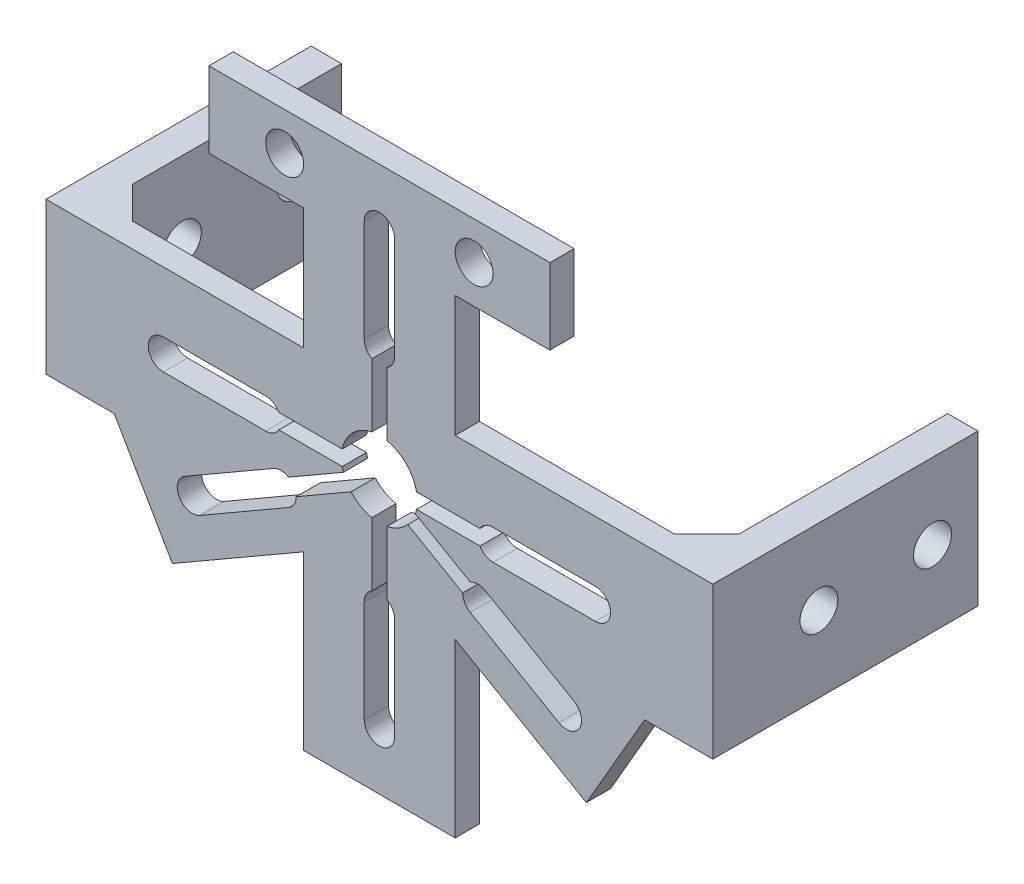
from build123d import *

# Parameters (mm, degrees)
BOSS_EXTRUDE1_DEPTH = 3.2
SKETCH2_W           = 4
SKETCH2_H           = 20
BOSS_EXTRUDE2_DEPTH = 35
BOSS_EXTRUDE3_DEPTH = 20
CUT_EXTRUDE1_REACH  = 102.256
SKETCH4_R           = 2.5
SKETCH5_R           = 2.5
CUT_EXTRUDE2_DEPTH  = 3.2


with BuildPart() as part:
    # Sketch1 → Boss-Extrude1 (new body)
    with BuildSketch(Plane.XY):
        Polygon((22.5, 36), (-22.5, 36), (-22.5, 26), (-10, 26), (-10, 10), (-40, 10), (-40, -10), (-35, -10), (-27.320508076, -23.301270189), (-10, -13.301270189), (-10, -36), (10, -36), (10, -13.301270189), (27.320508076, -23.301270189), (35, -10), (40, -10), (40, 10), (10, 10), (10, 26), (22.5, 26), align=None)
        with BuildLine():
            Line((2, 28.5), (2, 15))
            ThreePointArc((2, 15), (1.732050808, 14), (1, 13.267949192))
            Line((1, 13.267949192), (1, 4.898979486))
            ThreePointArc((1, 4.898979486), (3.535533906, 3.535533906), (4.898979486, 1))
            Line((4.898979486, 1), (13.267949192, 1))
            ThreePointArc((13.267949192, 1), (14, 1.732050808), (15, 2))
            Line((15, 2), (28.5, 2))
            ThreePointArc((28.5, 2), (30.5, 0), (28.5, -2))
            Line((28.5, -2), (15, -2))
            ThreePointArc((15, -2), (14, -1.732050808), (13.267949192, -1))
            Line((13.267949192, -1), (4.898979486, -1))
            ThreePointArc((4.898979486, -1), (4.829629131, -1.294095226), (4.742640687, -1.583464339))
            Line((4.742640687, -1.583464339), (11.990381057, -5.767949192))
            ThreePointArc((11.990381057, -5.767949192), (12.990381057, -5.5), (13.990381057, -5.767949192))
            Line((13.990381057, -5.767949192), (25.681724008, -12.517949192))
            ThreePointArc((25.681724008, -12.517949192), (26.413774815, -15.25), (23.681724008, -15.982050808))
            Line((23.681724008, -15.982050808), (11.990381057, -9.232050808))
            ThreePointArc((11.990381057, -9.232050808), (11.258330249, -8.5), (10.990381057, -7.5))
            Line((10.990381057, -7.5), (3.742640687, -3.315515147))
            ThreePointArc((3.742640687, -3.315515147), (2.5, -4.330127019), (1, -4.898979486))
            Line((1, -4.898979486), (1, -13.267949192))
            ThreePointArc((1, -13.267949192), (1.732050808, -14), (2, -15))
            Line((2, -15), (2, -28.5))
            ThreePointArc((2, -28.5), (0, -30.5), (-2, -28.5))
            Line((-2, -28.5), (-2, -15))
            ThreePointArc((-2, -15), (-1.732050808, -14), (-1, -13.267949192))
            Line((-1, -13.267949192), (-1, -4.898979486))
            ThreePointArc((-1, -4.898979486), (-2.5, -4.330127019), (-3.742640687, -3.315515147))
            Line((-3.742640687, -3.315515147), (-10.990381057, -7.5))
            ThreePointArc((-10.990381057, -7.5), (-11.258330249, -8.5), (-11.990381057, -9.232050808))
            Line((-11.990381057, -9.232050808), (-23.681724008, -15.982050808))
            ThreePointArc((-23.681724008, -15.982050808), (-26.413774815, -15.25), (-25.681724008, -12.517949192))
            Line((-25.681724008, -12.517949192), (-13.990381057, -5.767949192))
            ThreePointArc((-13.990381057, -5.767949192), (-12.990381057, -5.5), (-11.990381057, -5.767949192))
            Line((-11.990381057, -5.767949192), (-4.742640687, -1.583464339))
            ThreePointArc((-4.742640687, -1.583464339), (-4.829629131, -1.294095226), (-4.898979486, -1))
            Line((-4.898979486, -1), (-13.267949192, -1))
            ThreePointArc((-13.267949192, -1), (-14, -1.732050808), (-15, -2))
            Line((-15, -2), (-28.5, -2))
            ThreePointArc((-28.5, -2), (-30.5, 0), (-28.5, 2))
            Line((-28.5, 2), (-15, 2))
            ThreePointArc((-15, 2), (-14, 1.732050808), (-13.267949192, 1))
            Line((-13.267949192, 1), (-4.898979486, 1))
            ThreePointArc((-4.898979486, 1), (-3.535533906, 3.535533906), (-1, 4.898979486))
            Line((-1, 4.898979486), (-1, 13.267949192))
            ThreePointArc((-1, 13.267949192), (-1.732050808, 14), (-2, 15))
            Line((-2, 15), (-2, 28.5))
            ThreePointArc((-2, 28.5), (0, 30.5), (2, 28.5))
        make_face(mode=Mode.SUBTRACT)
    extrude(amount=BOSS_EXTRUDE1_DEPTH)

    # Sketch2 → Boss-Extrude2 (add)
    with BuildSketch(Plane(origin=(0, 0, 3.2), x_dir=(-1, 0, 0), z_dir=(0, 0, -1))):
        with Locations((42, 0)):
            Rectangle(SKETCH2_W, SKETCH2_H)
        with Locations((-42, 0)):
            Rectangle(SKETCH2_W, SKETCH2_H)
    extrude(amount=BOSS_EXTRUDE2_DEPTH)

    # Sketch3 → Boss-Extrude3 (add)
    with BuildSketch(Plane(origin=(0, 10, 0), x_dir=(1, 0, 0), z_dir=(0, 1, 0))):
        Polygon((-40, 4.242640687), (-35.757359313, 0), (-40, 0), align=None)
        Polygon((35.757359313, 0), (40, 0), (40, 4.242640687), align=None)
    extrude(amount=-BOSS_EXTRUDE3_DEPTH)

    # Cut-Extrude1: up to this face of the body (flat: up to its plane)
    cut_extrude1_end = Plane(part.part.faces().sort_by_distance((44, 0, -14.3))[0])
    # Sketch4 → Cut-Extrude1 (cut, up to the picked face)
    with BuildSketch(Plane.ZY.offset(44), mode=Mode.PRIVATE) as cut_extrude1_sk1:
        with Locations((-25.8, 0)):
            Circle(SKETCH4_R)
    cut_extrude1_tool1 = split(extrude(cut_extrude1_sk1.sketch, amount=-CUT_EXTRUDE1_REACH, mode=Mode.PRIVATE), bisect_by=cut_extrude1_end, keep=Keep.BOTH, mode=Mode.PRIVATE)
    # Sketch4 → Cut-Extrude1 (cut, up to the picked face)
    with BuildSketch(Plane.ZY.offset(44), mode=Mode.PRIVATE) as cut_extrude1_sk2:
        with Locations((-10.8, 0)):
            Circle(SKETCH4_R)
    cut_extrude1_tool2 = split(extrude(cut_extrude1_sk2.sketch, amount=-CUT_EXTRUDE1_REACH, mode=Mode.PRIVATE), bisect_by=cut_extrude1_end, keep=Keep.BOTH, mode=Mode.PRIVATE)
    add(cut_extrude1_tool1.solids().sort_by(Axis((-44, 0, -25.8), (1, 0, 0)))[0], mode=Mode.SUBTRACT)
    add(cut_extrude1_tool2.solids().sort_by(Axis((-44, 0, -10.8), (1, 0, 0)))[0], mode=Mode.SUBTRACT)

    # Sketch5 → Cut-Extrude2 (cut)
    with BuildSketch(Plane.XY.offset(3.2)):
        with Locations((-12.5, 31)):
            Circle(SKETCH5_R)
        with Locations((12.5, 31)):
            Circle(SKETCH5_R)
    extrude(amount=-CUT_EXTRUDE2_DEPTH, mode=Mode.SUBTRACT)


solid = part.part
